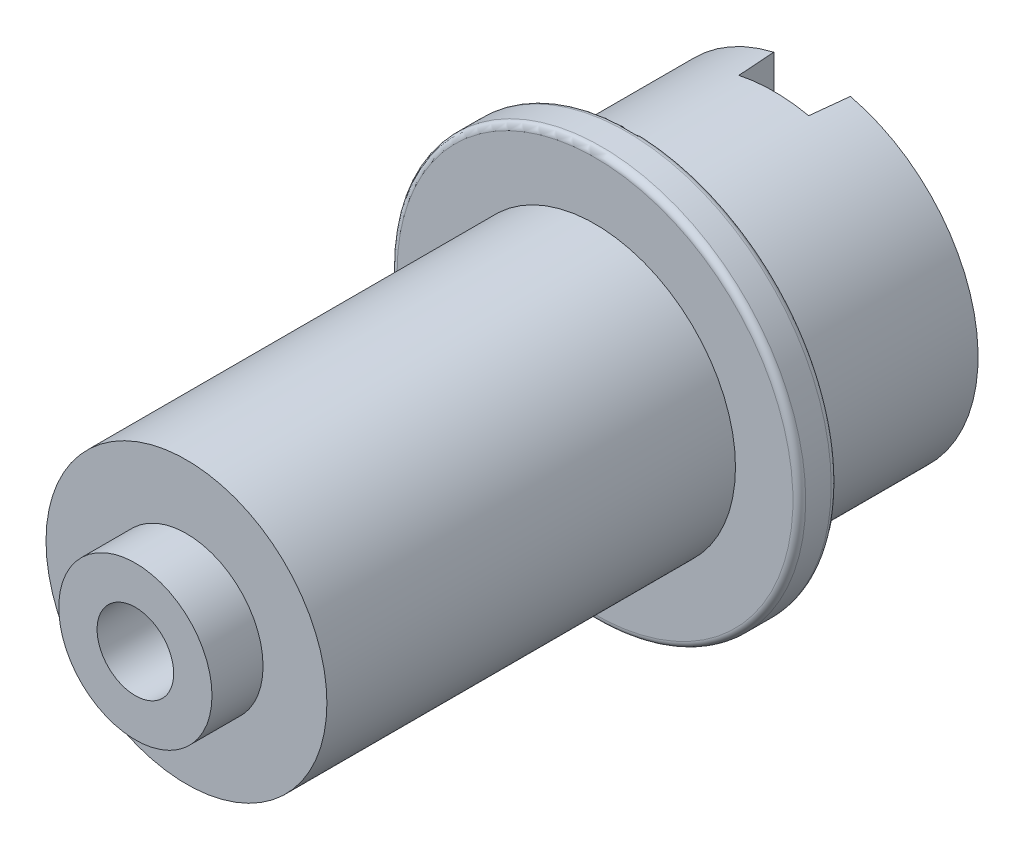
from build123d import *

# Parameters (mm, degrees)
ESQUISSE1_R             = 5.5
BASE_EXTRUSION_DEPTH    = 16
ESQUISSE2_R             = 3
BOSS_EXTRU_1_DEPTH      = 2
ESQUISSE3_R             = 8
BOSS_EXTRU_2_DEPTH      = 1.5
ESQUISSE4_R             = 6.5
BOSS_EXTRU_3_DEPTH      = 7
ESQUISSE5_R             = 4.5
ENL_V_MAT_EXTRU_1_DEPTH = 19
ESQUISSE6_W             = 3
ESQUISSE6_H             = 4
ENL_V_MAT_EXTRU_2_DEPTH = 1.5
ENL_V_MAT_EXTRU_2_TAPER = 5
BOSS_EXTRU_4_DEPTH      = 2
ENL_V_MAT_EXTRU_3_REACH = 17
ESQUISSE8_R             = 1.5
ESQUISSE9_R             = 1.5
ENL_V_MAT_EXTRU_4_DEPTH = 27.5000001
CONG_2_R                = 0.25


with BuildPart() as part:
    # Esquisse1 → Base-Extrusion (new body)
    with BuildSketch(Plane.XY):
        Circle(ESQUISSE1_R)
    extrude(amount=BASE_EXTRUSION_DEPTH)

    # Esquisse2 → Boss.-Extru.1 (add)
    with BuildSketch(Plane.XY.offset(16)):
        Circle(ESQUISSE2_R)
    extrude(amount=BOSS_EXTRU_1_DEPTH)

    # Esquisse3 → Boss.-Extru.2 (add)
    with BuildSketch(Plane(origin=(0, 0, 0), x_dir=(-1, 0, 0), z_dir=(0, 0, -1))):
        Circle(ESQUISSE3_R)
    extrude(amount=BOSS_EXTRU_2_DEPTH)

    # Esquisse4 → Boss.-Extru.3 (add)
    with BuildSketch(Plane(origin=(0, 0, -1.5), x_dir=(-1, 0, 0), z_dir=(0, 0, -1))):
        Circle(ESQUISSE4_R)
    extrude(amount=BOSS_EXTRU_3_DEPTH)

    # Esquisse5 → Enlèv. mat.-Extru.1 (cut)
    with BuildSketch(Plane(origin=(0, 0, -8.5), x_dir=(-1, 0, 0), z_dir=(0, 0, -1))):
        Circle(ESQUISSE5_R)
    extrude(amount=-ENL_V_MAT_EXTRU_1_DEPTH, mode=Mode.SUBTRACT)

    # Esquisse6 → Enlèv. mat.-Extru.2 (cut)
    with BuildSketch(Plane(origin=(0, 0, -8.5), x_dir=(-1, 0, 0), z_dir=(0, 0, -1))):
        with Locations((0, 5)):
            Rectangle(ESQUISSE6_W, ESQUISSE6_H)
    extrude(amount=-ENL_V_MAT_EXTRU_2_DEPTH, taper=ENL_V_MAT_EXTRU_2_TAPER, mode=Mode.SUBTRACT)

    # Esquisse7 → Boss.-Extru.4 (add)
    with BuildSketch(Plane(origin=(0, -5, 0), x_dir=(-1, 0, 0), z_dir=(0, 1, 0))):
        with BuildLine():
            Line((3, -5), (3, -1.5))
            Line((3, -1.5), (-3, -1.5))
            Line((-3, -1.5), (-3, -5))
            ThreePointArc((-3, -5), (0, -8), (3, -5))
        make_face()
    extrude(amount=-BOSS_EXTRU_4_DEPTH)

    # Esquisse8 → Enlèv. mat.-Extru.3 (cut, up to next)
    with BuildSketch(Plane.XZ.offset(7), mode=Mode.PRIVATE) as enl_v_mat_extru_3_sk1:
        with Locations((0, -5)):
            Circle(ESQUISSE8_R)
    enl_v_mat_extru_3_tool1 = extrude(enl_v_mat_extru_3_sk1.sketch, amount=-ENL_V_MAT_EXTRU_3_REACH, mode=Mode.PRIVATE) & part.part
    add(enl_v_mat_extru_3_tool1.solids().sort_by_distance((0, -7, -5))[0], mode=Mode.SUBTRACT)

    # Esquisse9 → Enlèv. mat.-Extru.4 (cut, through all)
    with BuildSketch(Plane.XY.offset(18)):
        Circle(ESQUISSE9_R)
    extrude(amount=-ENL_V_MAT_EXTRU_4_DEPTH, mode=Mode.SUBTRACT)

    # Congé2
    cong_2_edges = [part.edges().sort_by_distance(p)[0] for p in [
        (8, 0, 0),
        (8, 0, -1.5),
    ]]
    fillet(cong_2_edges, radius=CONG_2_R)


solid = part.part
